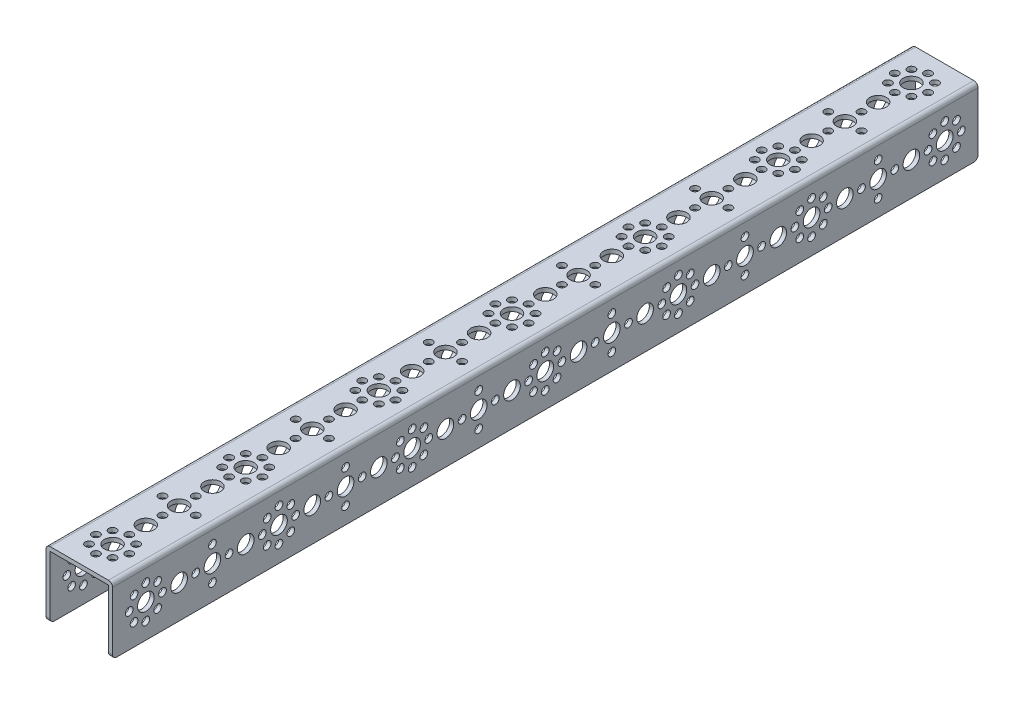
from build123d import *

# Parameters (mm, degrees)
BOSS_EXTRUDE1_DEPTH = 416
SKETCH2_R           = 4
SKETCH2_R_2         = 1.85
CUT_EXTRUDE1_DEPTH  = 33
SKETCH3_R           = 4
SKETCH3_R_2         = 1.85
CUT_EXTRUDE2_DEPTH  = 33
FILLET1_R           = 2


with BuildPart() as part:
    # Sketch1 → Boss-Extrude1 (new body)
    with BuildSketch(Plane.XY):
        Polygon((14, -16), (16, -16), (16, 16), (-16, 16), (-16, -16), (-14, -16), (-14, 14), (14, 14), align=None)
    extrude(amount=-BOSS_EXTRUDE1_DEPTH)

    # Sketch2 → Cut-Extrude1 (cut, through all)
    with BuildSketch(Plane(origin=(0, 16, 0), x_dir=(1, 0, 0), z_dir=(0, 1, 0))):
        with Locations((0, 256)):
            Circle(SKETCH2_R)
        with Locations((0, 224)):
            Circle(SKETCH2_R)
        with Locations((0.175415159, 192)):
            Circle(SKETCH2_R)
        with Locations((0, 160)):
            Circle(SKETCH2_R)
        with Locations((0, 240)):
            Circle(SKETCH2_R)
        with Locations((0, 232)):
            Circle(SKETCH2_R_2)
        with Locations((0, 248)):
            Circle(SKETCH2_R_2)
        with Locations((-8, 240)):
            Circle(SKETCH2_R_2)
        with Locations((8, 240)):
            Circle(SKETCH2_R_2)
        with Locations((0, 264)):
            Circle(SKETCH2_R_2)
        with Locations((-8, 272)):
            Circle(SKETCH2_R_2)
        with Locations((0, 272)):
            Circle(SKETCH2_R)
        with Locations((8, 272)):
            Circle(SKETCH2_R_2)
        with Locations((5.66, 277.66)):
            Circle(SKETCH2_R_2)
        with Locations((-5.66, 277.66)):
            Circle(SKETCH2_R_2)
        with Locations((0, 280)):
            Circle(SKETCH2_R_2)
        with Locations((5.66, 266.34)):
            Circle(SKETCH2_R_2)
        with Locations((-5.66, 266.34)):
            Circle(SKETCH2_R_2)
        with Locations((0, 176)):
            Circle(SKETCH2_R)
        with Locations((0, 168)):
            Circle(SKETCH2_R_2)
        with Locations((0, 184)):
            Circle(SKETCH2_R_2)
        with Locations((-8, 176)):
            Circle(SKETCH2_R_2)
        with Locations((8, 176)):
            Circle(SKETCH2_R_2)
        with Locations((0, 200)):
            Circle(SKETCH2_R_2)
        with Locations((-8, 208)):
            Circle(SKETCH2_R_2)
        with Locations((0, 208)):
            Circle(SKETCH2_R)
        with Locations((8, 208)):
            Circle(SKETCH2_R_2)
        with Locations((5.66, 213.66)):
            Circle(SKETCH2_R_2)
        with Locations((-5.66, 213.66)):
            Circle(SKETCH2_R_2)
        with Locations((0, 216)):
            Circle(SKETCH2_R_2)
        with Locations((5.66, 202.34)):
            Circle(SKETCH2_R_2)
        with Locations((-5.66, 202.34)):
            Circle(SKETCH2_R_2)
        with Locations((0, 32)):
            Circle(SKETCH2_R)
        with Locations((0, 64)):
            Circle(SKETCH2_R)
        with Locations((-0.175415159, 96)):
            Circle(SKETCH2_R)
        with Locations((0, 128)):
            Circle(SKETCH2_R)
        with Locations((0, 48)):
            Circle(SKETCH2_R)
        with Locations((0, 56)):
            Circle(SKETCH2_R_2)
        with Locations((0, 40)):
            Circle(SKETCH2_R_2)
        with Locations((8, 48)):
            Circle(SKETCH2_R_2)
        with Locations((-8, 48)):
            Circle(SKETCH2_R_2)
        with Locations((0, 24)):
            Circle(SKETCH2_R_2)
        with Locations((8, 16)):
            Circle(SKETCH2_R_2)
        with Locations((0, 16)):
            Circle(SKETCH2_R)
        with Locations((-8, 16)):
            Circle(SKETCH2_R_2)
        with Locations((-5.66, 10.34)):
            Circle(SKETCH2_R_2)
        with Locations((5.66, 10.34)):
            Circle(SKETCH2_R_2)
        with Locations((0, 8)):
            Circle(SKETCH2_R_2)
        with Locations((-5.66, 21.66)):
            Circle(SKETCH2_R_2)
        with Locations((5.66, 21.66)):
            Circle(SKETCH2_R_2)
        with Locations((0, 112)):
            Circle(SKETCH2_R)
        with Locations((0, 120)):
            Circle(SKETCH2_R_2)
        with Locations((0, 104)):
            Circle(SKETCH2_R_2)
        with Locations((8, 112)):
            Circle(SKETCH2_R_2)
        with Locations((-8, 112)):
            Circle(SKETCH2_R_2)
        with Locations((0, 88)):
            Circle(SKETCH2_R_2)
        with Locations((8, 80)):
            Circle(SKETCH2_R_2)
        with Locations((0, 80)):
            Circle(SKETCH2_R)
        with Locations((-8, 80)):
            Circle(SKETCH2_R_2)
        with Locations((-5.66, 74.34)):
            Circle(SKETCH2_R_2)
        with Locations((5.66, 74.34)):
            Circle(SKETCH2_R_2)
        with Locations((0, 72)):
            Circle(SKETCH2_R_2)
        with Locations((-5.66, 85.66)):
            Circle(SKETCH2_R_2)
        with Locations((5.66, 85.66)):
            Circle(SKETCH2_R_2)
        with Locations((0, 136)):
            Circle(SKETCH2_R_2)
        with Locations((-8, 144)):
            Circle(SKETCH2_R_2)
        with Locations((0, 144)):
            Circle(SKETCH2_R)
        with Locations((8, 144)):
            Circle(SKETCH2_R_2)
        with Locations((5.66, 149.66)):
            Circle(SKETCH2_R_2)
        with Locations((-5.66, 149.66)):
            Circle(SKETCH2_R_2)
        with Locations((0, 152)):
            Circle(SKETCH2_R_2)
        with Locations((5.66, 138.34)):
            Circle(SKETCH2_R_2)
        with Locations((-5.66, 138.34)):
            Circle(SKETCH2_R_2)
        with Locations((0, 384)):
            Circle(SKETCH2_R)
        with Locations((0, 352)):
            Circle(SKETCH2_R)
        with Locations((0.175415159, 320)):
            Circle(SKETCH2_R)
        with Locations((0, 288)):
            Circle(SKETCH2_R)
        with Locations((0, 368)):
            Circle(SKETCH2_R)
        with Locations((0, 360)):
            Circle(SKETCH2_R_2)
        with Locations((0, 376)):
            Circle(SKETCH2_R_2)
        with Locations((-8, 368)):
            Circle(SKETCH2_R_2)
        with Locations((8, 368)):
            Circle(SKETCH2_R_2)
        with Locations((0, 392)):
            Circle(SKETCH2_R_2)
        with Locations((-8, 400)):
            Circle(SKETCH2_R_2)
        with Locations((0, 400)):
            Circle(SKETCH2_R)
        with Locations((8, 400)):
            Circle(SKETCH2_R_2)
        with Locations((5.66, 405.66)):
            Circle(SKETCH2_R_2)
        with Locations((-5.66, 405.66)):
            Circle(SKETCH2_R_2)
        with Locations((0, 408)):
            Circle(SKETCH2_R_2)
        with Locations((5.66, 394.34)):
            Circle(SKETCH2_R_2)
        with Locations((-5.66, 394.34)):
            Circle(SKETCH2_R_2)
        with Locations((0, 304)):
            Circle(SKETCH2_R)
        with Locations((0, 296)):
            Circle(SKETCH2_R_2)
        with Locations((0, 312)):
            Circle(SKETCH2_R_2)
        with Locations((-8, 304)):
            Circle(SKETCH2_R_2)
        with Locations((8, 304)):
            Circle(SKETCH2_R_2)
        with Locations((0, 328)):
            Circle(SKETCH2_R_2)
        with Locations((-8, 336)):
            Circle(SKETCH2_R_2)
        with Locations((0, 336)):
            Circle(SKETCH2_R)
        with Locations((8, 336)):
            Circle(SKETCH2_R_2)
        with Locations((5.66, 341.66)):
            Circle(SKETCH2_R_2)
        with Locations((-5.66, 341.66)):
            Circle(SKETCH2_R_2)
        with Locations((0, 344)):
            Circle(SKETCH2_R_2)
        with Locations((5.66, 330.34)):
            Circle(SKETCH2_R_2)
        with Locations((-5.66, 330.34)):
            Circle(SKETCH2_R_2)
    extrude(amount=-CUT_EXTRUDE1_DEPTH, mode=Mode.SUBTRACT)

    # Sketch3 → Cut-Extrude2 (cut, through all)
    with BuildSketch(Plane(origin=(16, 0, 0), x_dir=(0, 0, -1), z_dir=(1, 0, 0))):
        with Locations((160, 0)):
            Circle(SKETCH3_R)
        with Locations((192, 0)):
            Circle(SKETCH3_R)
        with Locations((224, 0.175415159)):
            Circle(SKETCH3_R)
        with Locations((256, 0)):
            Circle(SKETCH3_R)
        with Locations((176, 0)):
            Circle(SKETCH3_R)
        with Locations((184, 0)):
            Circle(SKETCH3_R_2)
        with Locations((168, 0)):
            Circle(SKETCH3_R_2)
        with Locations((176, -8)):
            Circle(SKETCH3_R_2)
        with Locations((176, 8)):
            Circle(SKETCH3_R_2)
        with Locations((152, 0)):
            Circle(SKETCH3_R_2)
        with Locations((144, -8)):
            Circle(SKETCH3_R_2)
        with Locations((144, 0)):
            Circle(SKETCH3_R)
        with Locations((144, 8)):
            Circle(SKETCH3_R_2)
        with Locations((138.34, 5.66)):
            Circle(SKETCH3_R_2)
        with Locations((138.34, -5.66)):
            Circle(SKETCH3_R_2)
        with Locations((136, 0)):
            Circle(SKETCH3_R_2)
        with Locations((149.66, 5.66)):
            Circle(SKETCH3_R_2)
        with Locations((149.66, -5.66)):
            Circle(SKETCH3_R_2)
        with Locations((240, 0)):
            Circle(SKETCH3_R)
        with Locations((248, 0)):
            Circle(SKETCH3_R_2)
        with Locations((232, 0)):
            Circle(SKETCH3_R_2)
        with Locations((240, -8)):
            Circle(SKETCH3_R_2)
        with Locations((240, 8)):
            Circle(SKETCH3_R_2)
        with Locations((216, 0)):
            Circle(SKETCH3_R_2)
        with Locations((208, -8)):
            Circle(SKETCH3_R_2)
        with Locations((208, 0)):
            Circle(SKETCH3_R)
        with Locations((208, 8)):
            Circle(SKETCH3_R_2)
        with Locations((202.34, 5.66)):
            Circle(SKETCH3_R_2)
        with Locations((202.34, -5.66)):
            Circle(SKETCH3_R_2)
        with Locations((200, 0)):
            Circle(SKETCH3_R_2)
        with Locations((213.66, 5.66)):
            Circle(SKETCH3_R_2)
        with Locations((213.66, -5.66)):
            Circle(SKETCH3_R_2)
        with Locations((384, 0)):
            Circle(SKETCH3_R)
        with Locations((352, 0)):
            Circle(SKETCH3_R)
        with Locations((320, -0.175415159)):
            Circle(SKETCH3_R)
        with Locations((288, 0)):
            Circle(SKETCH3_R)
        with Locations((368, 0)):
            Circle(SKETCH3_R)
        with Locations((360, 0)):
            Circle(SKETCH3_R_2)
        with Locations((376, 0)):
            Circle(SKETCH3_R_2)
        with Locations((368, 8)):
            Circle(SKETCH3_R_2)
        with Locations((368, -8)):
            Circle(SKETCH3_R_2)
        with Locations((392, 0)):
            Circle(SKETCH3_R_2)
        with Locations((400, 8)):
            Circle(SKETCH3_R_2)
        with Locations((400, 0)):
            Circle(SKETCH3_R)
        with Locations((400, -8)):
            Circle(SKETCH3_R_2)
        with Locations((405.66, -5.66)):
            Circle(SKETCH3_R_2)
        with Locations((405.66, 5.66)):
            Circle(SKETCH3_R_2)
        with Locations((408, 0)):
            Circle(SKETCH3_R_2)
        with Locations((394.34, -5.66)):
            Circle(SKETCH3_R_2)
        with Locations((394.34, 5.66)):
            Circle(SKETCH3_R_2)
        with Locations((304, 0)):
            Circle(SKETCH3_R)
        with Locations((296, 0)):
            Circle(SKETCH3_R_2)
        with Locations((312, 0)):
            Circle(SKETCH3_R_2)
        with Locations((304, 8)):
            Circle(SKETCH3_R_2)
        with Locations((304, -8)):
            Circle(SKETCH3_R_2)
        with Locations((328, 0)):
            Circle(SKETCH3_R_2)
        with Locations((336, 8)):
            Circle(SKETCH3_R_2)
        with Locations((336, 0)):
            Circle(SKETCH3_R)
        with Locations((336, -8)):
            Circle(SKETCH3_R_2)
        with Locations((341.66, -5.66)):
            Circle(SKETCH3_R_2)
        with Locations((341.66, 5.66)):
            Circle(SKETCH3_R_2)
        with Locations((344, 0)):
            Circle(SKETCH3_R_2)
        with Locations((330.34, -5.66)):
            Circle(SKETCH3_R_2)
        with Locations((330.34, 5.66)):
            Circle(SKETCH3_R_2)
        with Locations((280, 0)):
            Circle(SKETCH3_R_2)
        with Locations((272, -8)):
            Circle(SKETCH3_R_2)
        with Locations((272, 0)):
            Circle(SKETCH3_R)
        with Locations((272, 8)):
            Circle(SKETCH3_R_2)
        with Locations((266.34, 5.66)):
            Circle(SKETCH3_R_2)
        with Locations((266.34, -5.66)):
            Circle(SKETCH3_R_2)
        with Locations((264, 0)):
            Circle(SKETCH3_R_2)
        with Locations((277.66, 5.66)):
            Circle(SKETCH3_R_2)
        with Locations((277.66, -5.66)):
            Circle(SKETCH3_R_2)
        with Locations((32, 0)):
            Circle(SKETCH3_R)
        with Locations((64, 0)):
            Circle(SKETCH3_R)
        with Locations((96, 0.175415159)):
            Circle(SKETCH3_R)
        with Locations((128, 0)):
            Circle(SKETCH3_R)
        with Locations((48, 0)):
            Circle(SKETCH3_R)
        with Locations((56, 0)):
            Circle(SKETCH3_R_2)
        with Locations((40, 0)):
            Circle(SKETCH3_R_2)
        with Locations((48, -8)):
            Circle(SKETCH3_R_2)
        with Locations((48, 8)):
            Circle(SKETCH3_R_2)
        with Locations((24, 0)):
            Circle(SKETCH3_R_2)
        with Locations((16, -8)):
            Circle(SKETCH3_R_2)
        with Locations((16, 0)):
            Circle(SKETCH3_R)
        with Locations((16, 8)):
            Circle(SKETCH3_R_2)
        with Locations((10.34, 5.66)):
            Circle(SKETCH3_R_2)
        with Locations((10.34, -5.66)):
            Circle(SKETCH3_R_2)
        with Locations((8, 0)):
            Circle(SKETCH3_R_2)
        with Locations((21.66, 5.66)):
            Circle(SKETCH3_R_2)
        with Locations((21.66, -5.66)):
            Circle(SKETCH3_R_2)
        with Locations((112, 0)):
            Circle(SKETCH3_R)
        with Locations((120, 0)):
            Circle(SKETCH3_R_2)
        with Locations((104, 0)):
            Circle(SKETCH3_R_2)
        with Locations((112, -8)):
            Circle(SKETCH3_R_2)
        with Locations((112, 8)):
            Circle(SKETCH3_R_2)
        with Locations((88, 0)):
            Circle(SKETCH3_R_2)
        with Locations((80, -8)):
            Circle(SKETCH3_R_2)
        with Locations((80, 0)):
            Circle(SKETCH3_R)
        with Locations((80, 8)):
            Circle(SKETCH3_R_2)
        with Locations((74.34, 5.66)):
            Circle(SKETCH3_R_2)
        with Locations((74.34, -5.66)):
            Circle(SKETCH3_R_2)
        with Locations((72, 0)):
            Circle(SKETCH3_R_2)
        with Locations((85.66, 5.66)):
            Circle(SKETCH3_R_2)
        with Locations((85.66, -5.66)):
            Circle(SKETCH3_R_2)
    extrude(amount=-CUT_EXTRUDE2_DEPTH, mode=Mode.SUBTRACT)

    # Fillet1
    fillet1_edges = [part.edges().sort_by_distance(p)[0] for p in [
        (-15, -16, -416),
        (-16, 16, -208),
        (16, 16, -208),
        (15, -16, -416),
        (15, -16, 0),
        (-15, -16, 0),
    ]]
    fillet(fillet1_edges, radius=FILLET1_R)


solid = part.part
